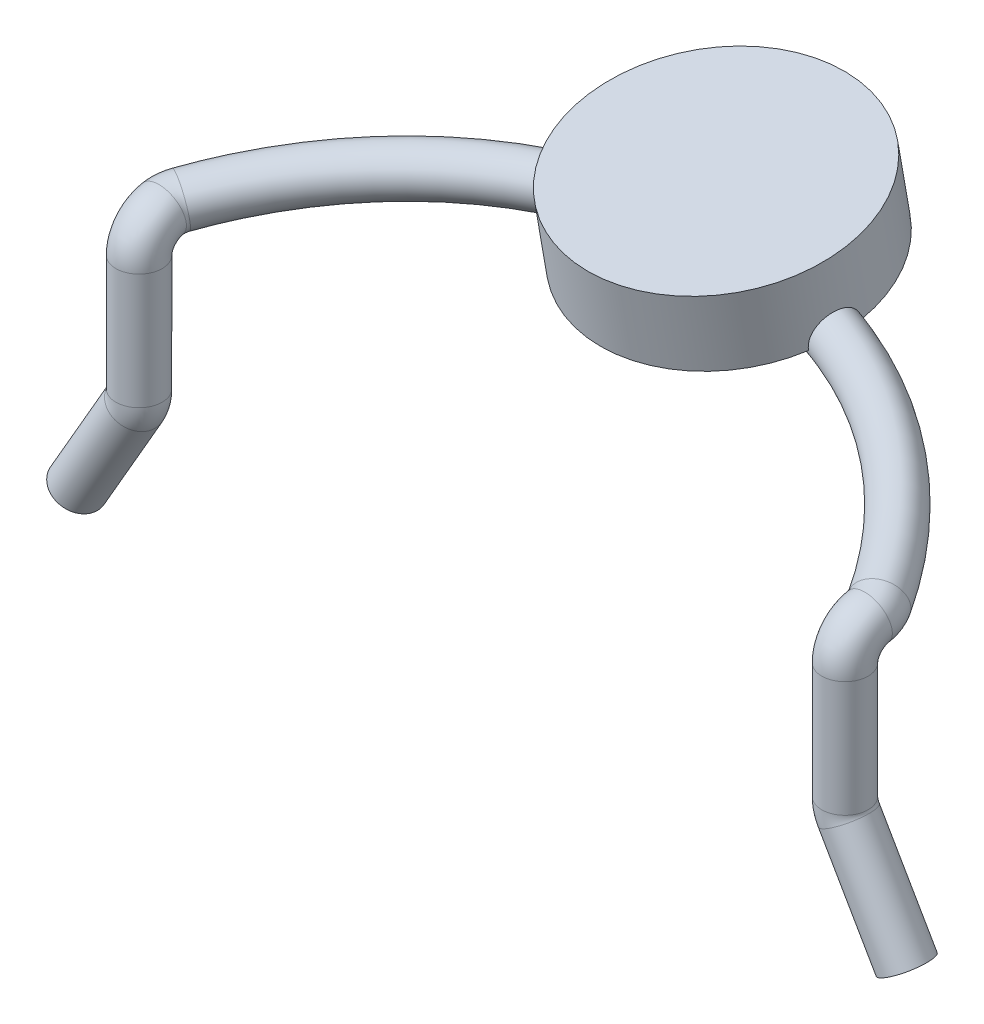
from build123d import *

# Parameters (mm, degrees)
SKETCH1_R             = 0.4
BOSS_EXTRUDE1_DEPTH   = 2
BOSS_EXTRUDE1_2_DEPTH = 2
SKETCH2_R             = 0.4
REVOLVE4_ANGLE        = 80
SKETCH3_R             = 0.4
REVOLVE5_ANGLE        = 30
SKETCH4_R             = 0.4
REVOLVE6_ANGLE        = 30
SKETCH11_R            = 0.4
SKETCH12_R            = 2.25
BOSS_EXTRUDE2_DEPTH   = 1.25
SKETCH13_R            = 0.4
REVOLVE7_ANGLE        = 30
SKETCH14_R            = 0.4
BOSS_EXTRUDE3_DEPTH   = 2


with BuildPart() as part:
    # Sketch1 → Boss-Extrude1 (new body)
    with BuildSketch(Plane(origin=(0, 0, 0), x_dir=(1, 0, 0), z_dir=(0, 1, 0))):
        with Locations(Location((-6.1, 0, 0), (0, 0, 270))):
            Circle(SKETCH1_R)
    extrude(amount=-BOSS_EXTRUDE1_DEPTH)



with BuildPart() as body_2:
    # Sketch1 → Boss-Extrude1 2 (new body)
    with BuildSketch(Plane(origin=(0, 0, 0), x_dir=(1, 0, 0), z_dir=(0, 1, 0))):
        with Locations(Location((6.1, 0, 0), (0, 0, 270))):
            Circle(SKETCH1_R)
    extrude(amount=-BOSS_EXTRUDE1_2_DEPTH)


with BuildPart() as part_1:
    add(part.part)

    add(body_2.part)  # Revolve4 merges body 2
    # Sketch2 → Revolve4 (revolve)
    with BuildSketch(Plane(origin=(0, 0, 0), x_dir=(1, 0, 0), z_dir=(0, 1, 0))):
        with Locations(Location((6.1, 0, 0), (0, 0, 270))):
            Circle(SKETCH2_R)
        with Locations(Location((-6.1, 0, 0), (0, 0, 270))):
            Circle(SKETCH2_R)
    revolve(axis=Axis((-6.5, 0, -0.5), (-1, 0, 0)), revolution_arc=REVOLVE4_ANGLE)

    # Sketch3 → Revolve5 (revolve)
    with BuildSketch(Plane(origin=(0, 0.085505036, -0.484923155), x_dir=(-1, 0, 0), z_dir=(0, 0.17364817766692736, -0.9848077530122086))):
        with Locations((-6.1, 0.413175911)):
            Circle(SKETCH3_R)
    revolve(axis=Axis((5.6, 0.982265488, -0.326800092), (0, 0.9848077530122086, 0.1736481776669274)), revolution_arc=REVOLVE5_ANGLE)

    # Sketch4 → Revolve6 (revolve)
    with BuildSketch(Plane(origin=(0, 0.085505036, -0.484923155), x_dir=(-1, 0, 0), z_dir=(0, 0.17364817766692736, -0.9848077530122086))):
        with Locations((6.1, 0.413175911)):
            Circle(SKETCH4_R)
    revolve(axis=Axis((-5.6, 1.037409724, -0.317076676), (0, -0.9848077530122086, -0.17364817766692733)), revolution_arc=REVOLVE6_ANGLE)

    # Sweep1: sweep along a path in Sketch5
    with BuildLine(Plane(origin=(0, 0.406898841, 0.071747244), x_dir=(1, 0, 0), z_dir=(0, 0.984807753012208, 0.17364817766693072))) as sweep1_path:
        ThreePointArc((-6.033012702, 0.742403877), (0, 4.225565384), (6.033012702, 0.742403877))
    # Sketch11 → Sweep1 (sweep)
    with BuildSketch(Plane(origin=(-1.186782867, -0.356945676, 2.024339523), x_dir=(-0.8402936458397423, -0.15403461860121453, -0.5197883463812287), z_dir=(0.5000000000000008, 0.15038373318043258, -0.8528685319524433))):
        with Locations((5.32970496, 1.754864912)):
            Circle(SKETCH11_R)
    sweep(path=sweep1_path.line)

    # Sketch12 → Boss-Extrude2 (add)
    with BuildSketch(Plane(origin=(0, 0.406898841, 0.071747244), x_dir=(1, 0, 0), z_dir=(0, 0.984807753012208, 0.17364817766693072))):
        with Locations(Location((0, 4.225565384, 0), (0, 0, 178.774322398))):
            Circle(SKETCH12_R)
    extrude(amount=BOSS_EXTRUDE2_DEPTH)

    # Sketch13 → Revolve7 (revolve)
    with BuildSketch(Plane.XZ.offset(2)):
        with Locations(Location((6.1, 0, 0), (0, 0, 90))):
            Circle(SKETCH13_R)
    revolve7 = revolve(axis=Axis((6.6, -2, -0.291841751), (0, 0, 1)), revolution_arc=REVOLVE7_ANGLE)

    # Sketch14 → Boss-Extrude3 (add)
    with BuildSketch(Plane(origin=(2.516025404, -4.357883832, 0), x_dir=(0.866025403784438, 0.500000000000001, 0), z_dir=(0.500000000000001, -0.866025403784438, 0))):
        with Locations(Location((4.215767665, 0, 0), (0, 0, 180))):
            Circle(SKETCH14_R)
    boss_extrude3 = extrude(amount=BOSS_EXTRUDE3_DEPTH)

    # Mirror1: Revolve7, Boss-Extrude3 across plane
    add(revolve7.mirror(Plane(origin=(0, 0, 0), x_dir=(0, 0, 1), z_dir=(1, 0, 0))))
    add(boss_extrude3.mirror(Plane(origin=(0, 0, 0), x_dir=(0, 0, 1), z_dir=(1, 0, 0))))


solid = part_1.part
